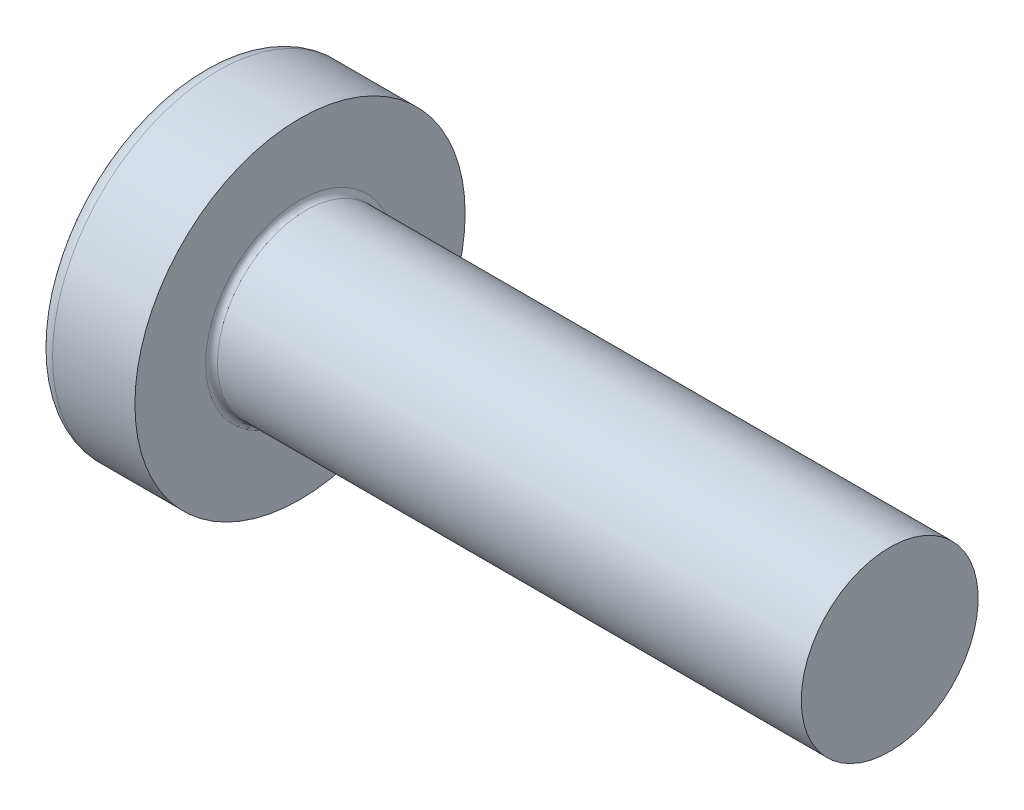
from build123d import *

# Parameters (mm, degrees)
FILLET1_R    = 0.1
SKETCH3_W    = 0.74
SKETCH3_H    = 2.8
SKETCH4_W    = 0.74
SKETCH4_H    = 1.054964664
RECPAT_COUNT = 2
RECPAT_ANGLE = 90


with BuildPart() as part:
    # BodySke → Base-Revolve (revolve)
    with BuildSketch(Plane.XY):
        with BuildLine():
            Line((2.4, 1.5), (2.4, 2.8))
            Line((2.4, 2.8), (1.003501533, 2.8))
            ThreePointArc((1.003501533, 2.8), (0.873295971, 2.76653015), (0.775371599, 2.674418605))
            ThreePointArc((0.775371599, 2.674418605), (0.197753546, 1.392274756), (0, 0))
            Line((0, 0), (12.4, 0))
            Line((12.4, 0), (12.4, 1.5))
            Line((12.4, 1.5), (2.4, 1.5))
        make_face()
    revolve(axis=Axis((-25.4, 0, 0), (1, 0, 0)))

    # Fillet1
    fillet1_edges = [part.edges().sort_by_distance(p)[0] for p in [
        (2.4, -1.5, 0),
    ]]
    fillet(fillet1_edges, radius=FILLET1_R)

    # Sketch3 → Recess section 0
    with BuildSketch(Plane(origin=(0, 0, 0), x_dir=(0, 0, -1), z_dir=(1, 0, 0))):
        Rectangle(SKETCH3_W, SKETCH3_H)
    # Sketch4 → Recess section 1
    with BuildSketch(Plane(origin=(1.75, 0, 0), x_dir=(0, 0, -1), z_dir=(1, 0, 0))):
        Rectangle(SKETCH4_W, SKETCH4_H)
    recess = loft(mode=Mode.SUBTRACT)

    # RecPat: Recess ×2 about axis
    recpat_axis = Axis((0, 0, 0), (1, 0, 0))
    for i in range(1, RECPAT_COUNT):
        add(recess.rotate(recpat_axis, i * RECPAT_ANGLE / (RECPAT_COUNT - 1)), mode=Mode.SUBTRACT)

    # RecCorSke → RecessCore (revolve, cut)
    with BuildSketch(Plane.XY):
        Polygon((0, 0), (0, 0.678371921), (1.75, 0.556), (1.930655351, 0), align=None)
    revolve(axis=Axis((-3.175, 0, 0), (1, 0, 0)), mode=Mode.SUBTRACT)


solid = part.part
